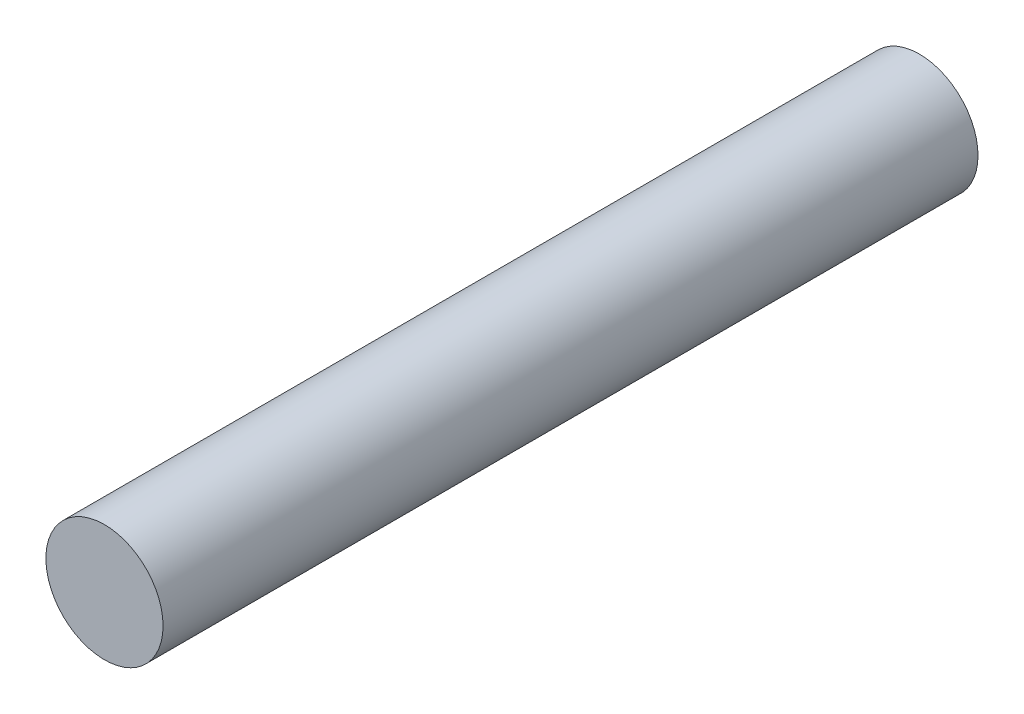
from build123d import *

# Parameters (mm, degrees)
SKETCH1_R           = 0.5715
BOSS_EXTRUDE1_DEPTH = 7.9502


with BuildPart() as part:
    # Sketch1 → Boss-Extrude1 (new body)
    with BuildSketch(Plane.XY):
        Circle(SKETCH1_R)
    extrude(amount=BOSS_EXTRUDE1_DEPTH)


solid = part.part
